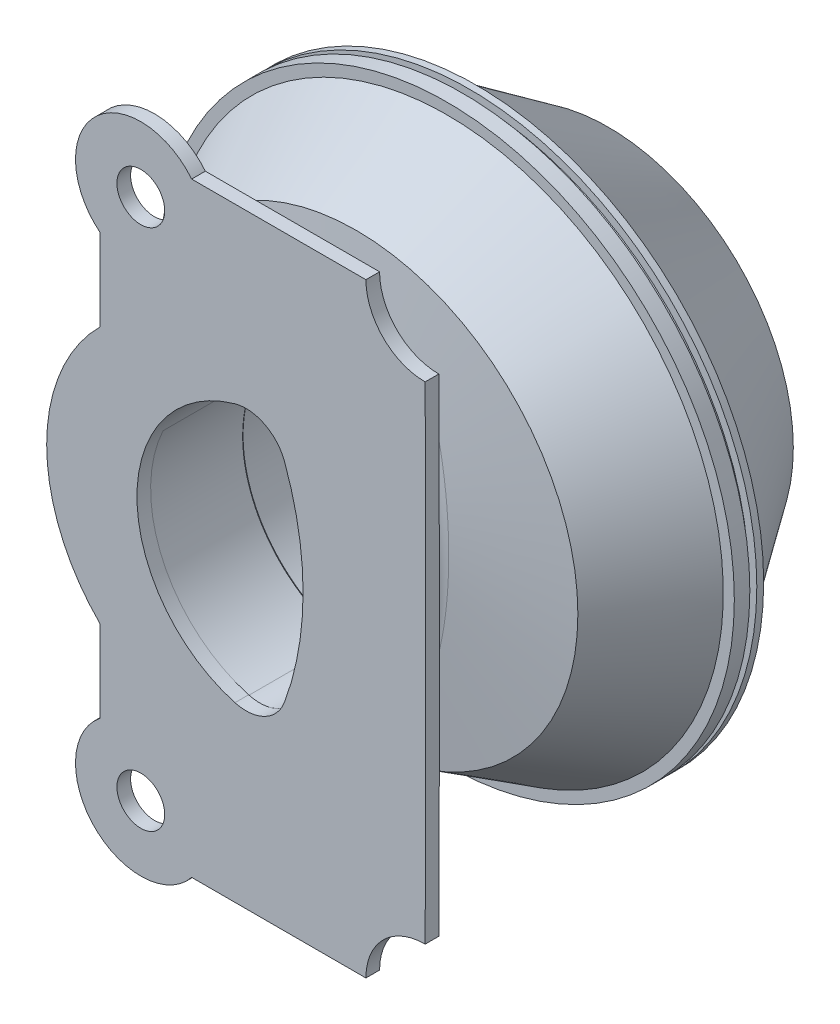
from build123d import *

# Parameters (mm, degrees)
EXTRUDE1_DEPTH             = 15.24
EXTRUDE1_DIRECTION_2_REACH = 59.31
FILLET1_R                  = 2.54
EXTRUDE2_DEPTH             = 2.54
CUT_EXTRUDE1_REACH         = 77.09
SKETCH4_R                  = 4.445
FILLET2_R                  = 2.54
SKETCH5_R                  = 10.951786425
CUT_EXTRUDE2_DEPTH         = 2.54
CUT_EXTRUDE3_DEPTH         = 30.48


with BuildPart() as part:
    # Sketch1 → Revolve1 (revolve)
    with BuildSketch(Plane(origin=(0, 0, 0), x_dir=(1, 0, 0), z_dir=(0, 1, 0))):
        Polygon((0, 0), (-41.188469602, 4.299895178), (-51.359146737, 21.168335306), (-53.409224319, 21.168335306), (-53.409224319, 24.051610794), (-51.938207547, 24.051610794), (-51.938207547, 25.346750524), (-53.409224319, 25.346750524), (-53.409224319, 26.625015442), (-51.467774531, 26.625015442), (-34.399161426, 51.146121593), (0, 57.310133178), align=None)
    revolve(axis=Axis((0, 0, -57.310133178), (0, 0, 1)))

    # Sketch2 → Extrude1 (add)
    with BuildSketch(Plane.XY):
        with BuildLine():
            ThreePointArc((13.411893858, 20.931515801), (17.172951087, -0.184502967), (13.411893858, -21.300521735))
            ThreePointArc((13.411893858, -21.300521735), (7.264097814, -28.228519168), (-1.953473188, -29.138974794))
            ThreePointArc((-1.953473188, -29.138974794), (-23.873112049, -0.184502967), (-1.953473188, 28.769968859))
            ThreePointArc((-1.953473188, 28.769968859), (7.264097814, 27.859513233), (13.411893858, 20.931515801))
        make_face()
        with BuildLine():
            ThreePointArc((-0.574915786, 23.880594718), (-18.793112049, -0.184502967), (-0.574915786, -24.249600653))
            ThreePointArc((-0.574915786, -24.249600653), (4.955626815, -23.703327277), (8.644304441, -19.546528818))
            ThreePointArc((8.644304441, -19.546528818), (12.092951087, -0.184502967), (8.644304441, 19.177522883))
            ThreePointArc((8.644304441, 19.177522883), (4.955626815, 23.334321343), (-0.574915786, 23.880594718))
        make_face(mode=Mode.SUBTRACT)
    extrude(amount=EXTRUDE1_DEPTH)

    # Sketch2 → Extrude1 direction 2 (add, up to next)
    with BuildSketch(Plane.XY, mode=Mode.PRIVATE) as extrude1_direction_2_sk1:
        with BuildLine():
            ThreePointArc((13.411893858, 20.931515801), (17.172951087, -0.184502967), (13.411893858, -21.300521735))
            ThreePointArc((13.411893858, -21.300521735), (7.264097814, -28.228519168), (-1.953473188, -29.138974794))
            ThreePointArc((-1.953473188, -29.138974794), (-23.873112049, -0.184502967), (-1.953473188, 28.769968859))
            ThreePointArc((-1.953473188, 28.769968859), (7.264097814, 27.859513233), (13.411893858, 20.931515801))
        make_face()
        with BuildLine():
            ThreePointArc((-0.574915786, 23.880594718), (-18.793112049, -0.184502967), (-0.574915786, -24.249600653))
            ThreePointArc((-0.574915786, -24.249600653), (4.955626815, -23.703327277), (8.644304441, -19.546528818))
            ThreePointArc((8.644304441, -19.546528818), (12.092951087, -0.184502967), (8.644304441, 19.177522883))
            ThreePointArc((8.644304441, 19.177522883), (4.955626815, 23.334321343), (-0.574915786, 23.880594718))
        make_face(mode=Mode.SUBTRACT)
    extrude1_direction_2_tool1 = extrude(extrude1_direction_2_sk1.sketch, amount=-EXTRUDE1_DIRECTION_2_REACH, mode=Mode.PRIVATE) - part.part
    add(extrude1_direction_2_tool1.solids().sort_by_distance((6.938003, 27.220284, 0))[0])

    # Fillet1
    fillet1_edges = [part.edges().sort_by_distance(p)[0] for p in [
        (-17.718528852, 18.047939889, -2.640351207),
        (7.268000448, 27.857521507, -3.00555169),
        (17.172951085, -0.185017625, -1.792884653),
        (7.268090901, -28.226481259, -3.042839778),
    ]]
    fillet(fillet1_edges, radius=FILLET1_R)

    # Sketch3 → Extrude2 (add)
    with BuildSketch(Plane.XY.offset(15.24)):
        with BuildLine():
            Line((-25.608688193, 23.860681658), (-25.608688193, 39.144891927))
            ThreePointArc((-25.608688193, 39.144891927), (-26.575402371, 57.186706355), (-8.533587943, 56.219992177))
            Line((-8.533587943, 56.219992177), (34.811648227, 56.219992177))
            ThreePointArc((34.811648227, 56.219992177), (34.988483556, 0), (34.811648227, -56.219992177))
            Line((34.811648227, -56.219992177), (-8.533587943, -56.219992177))
            ThreePointArc((-8.533587943, -56.219992177), (-26.575402371, -57.186706355), (-25.608688193, -39.144891927))
            Line((-25.608688193, -39.144891927), (-25.608688193, -23.860681658))
            ThreePointArc((-25.608688193, -23.860681658), (-35.492106143, 0), (-25.608688193, 23.860681658))
        make_face()
    extrude(amount=EXTRUDE2_DEPTH)

    # Sketch4 → Cut-Extrude1 (cut, up to next)
    with BuildSketch(Plane(origin=(173.745861831, 16.014786193, 17.78), x_dir=(1, 0, 0), z_dir=(0, 0, 1)), mode=Mode.PRIVATE) as cut_extrude1_sk1:
        with Locations((-191.734550024, 32.585205985)):
            Circle(SKETCH4_R)
    cut_extrude1_tool1 = extrude(cut_extrude1_sk1.sketch, amount=-CUT_EXTRUDE1_REACH, mode=Mode.PRIVATE) & part.part
    add(cut_extrude1_tool1.solids().sort_by_distance((-17.988688, 48.599992, 17.78))[0], mode=Mode.SUBTRACT)
    # Sketch4 → Cut-Extrude1 (cut, up to next)
    with BuildSketch(Plane(origin=(173.745861831, 16.014786193, 17.78), x_dir=(1, 0, 0), z_dir=(0, 0, 1)), mode=Mode.PRIVATE) as cut_extrude1_sk2:
        with Locations((-191.734550024, -64.61477837)):
            Circle(SKETCH4_R)
    cut_extrude1_tool2 = extrude(cut_extrude1_sk2.sketch, amount=-CUT_EXTRUDE1_REACH, mode=Mode.PRIVATE) & part.part
    add(cut_extrude1_tool2.solids().sort_by_distance((-17.988688, -48.599992, 17.78))[0], mode=Mode.SUBTRACT)

    # Fillet2
    fillet2_edges = [part.edges().sort_by_distance(p)[0] for p in [
        (17.172951087, -0.184502967, 15.24),
        (7.264097814, -28.228519168, 15.24),
        (7.264097814, 27.859513233, 15.24),
        (-23.873112049, -0.184502967, 15.24),
    ]]
    fillet(fillet2_edges, radius=FILLET2_R)

    # Sketch5 → Cut-Extrude2 (cut)
    with BuildSketch(Plane.XY.offset(17.78)):
        with Locations((34.811648227, 56.219992177)):
            Circle(SKETCH5_R)
        with Locations((34.811648227, -56.219992177)):
            Circle(SKETCH5_R)
    extrude(amount=-CUT_EXTRUDE2_DEPTH, mode=Mode.SUBTRACT)

    # Sketch6 → Cut-Extrude3 (cut)
    with BuildSketch(Plane(origin=(25.895888901, 34.92585125, 17.78), x_dir=(1, 0, 0), z_dir=(0, 0, 1))):
        with BuildLine():
            ThreePointArc((-26.384545334, -10.860753565), (-44.602741596, -34.92585125), (-26.384545334, -58.990948936))
            ThreePointArc((-26.384545334, -58.990948936), (-20.854002732, -58.44467556), (-17.165325106, -54.287877101))
            ThreePointArc((-17.165325106, -54.287877101), (-13.71667846, -34.92585125), (-17.165325106, -15.5638254))
            ThreePointArc((-17.165325106, -15.5638254), (-20.854002732, -11.40702694), (-26.384545334, -10.860753565))
        make_face()
    extrude(amount=-CUT_EXTRUDE3_DEPTH, mode=Mode.SUBTRACT)


solid = part.part
